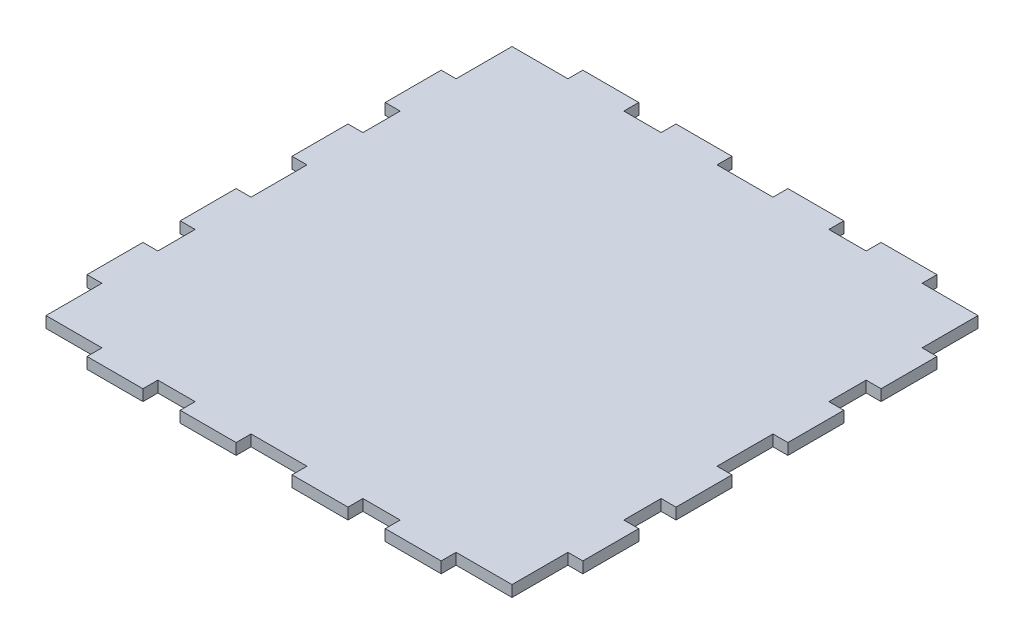
from build123d import *

# Parameters (mm, degrees)
BOSS_EXTRUDE1_DEPTH = 3


with BuildPart() as part:
    # Sketch1 → Boss-Extrude1 (new body)
    with BuildSketch(Plane(origin=(0, 0, 0), x_dir=(1, 0, 0), z_dir=(0, 1, 0))):
        Polygon((7.5, -62.5), (7.5, -66.5), (22.5, -66.5), (22.5, -62.5), (32.5, -62.5), (32.5, -66.5), (47.5, -66.5), (47.5, -62.5), (57.5, -62.5), (62.5, -62.5), (62.5, -59), (62.5, -47.5), (66.5, -47.5), (66.5, -32.5), (62.5, -32.5), (62.5, -22.5), (66.5, -22.5), (66.5, -7.5), (62.5, -7.5), (62.5, 7.5), (66.5, 7.5), (66.5, 22.5), (62.5, 22.5), (62.5, 32.5), (66.5, 32.5), (66.5, 47.5), (62.5, 47.5), (62.5, 59), (62.5, 62.5), (57.5, 62.5), (47.5, 62.5), (47.5, 66.5), (32.5, 66.5), (32.5, 62.5), (22.5, 62.5), (22.5, 66.5), (7.5, 66.5), (7.5, 62.5), (-7.5, 62.5), (-7.5, 66.5), (-22.5, 66.5), (-22.5, 62.5), (-32.5, 62.5), (-32.5, 66.5), (-47.5, 66.5), (-47.5, 62.5), (-59, 62.5), (-62.5, 62.5), (-62.5, 59), (-62.5, 47.5), (-66.5, 47.5), (-66.5, 32.5), (-62.5, 32.5), (-62.5, 22.5), (-66.5, 22.5), (-66.5, 7.5), (-62.5, 7.5), (-62.5, -7.5), (-66.5, -7.5), (-66.5, -22.5), (-62.5, -22.5), (-62.5, -32.5), (-66.5, -32.5), (-66.5, -47.5), (-62.5, -47.5), (-62.5, -59), (-62.5, -62.5), (-59, -62.5), (-47.5, -62.5), (-47.5, -66.5), (-32.5, -66.5), (-32.5, -62.5), (-22.5, -62.5), (-22.5, -66.5), (-7.5, -66.5), (-7.5, -62.5), align=None)
    extrude(amount=BOSS_EXTRUDE1_DEPTH)


solid = part.part
